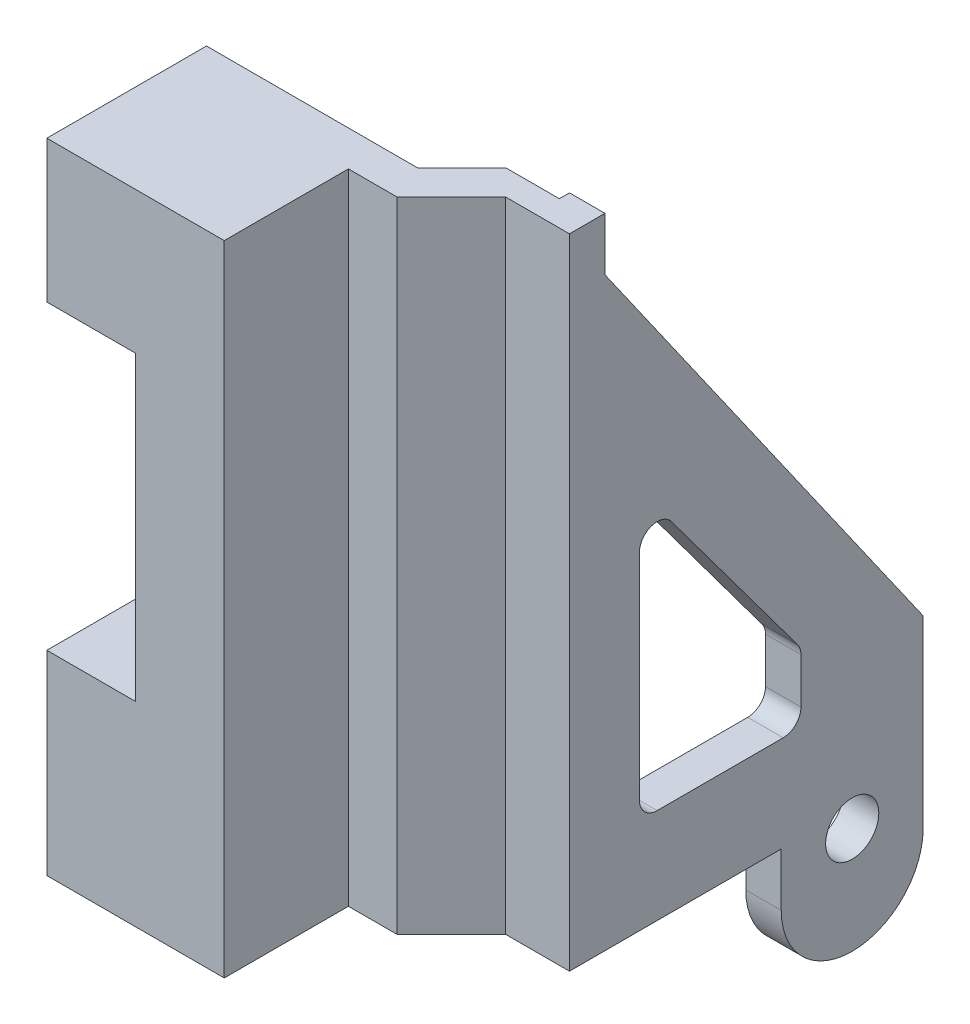
from build123d import *

# Parameters (mm, degrees)
BOSS_EXTRUDE1_DEPTH = 36
CUT_EXTRUDE1_REACH  = 21.399
CUT_EXTRUDE2_REACH  = 21.399
BOSS_EXTRUDE2_DEPTH = 2
CUT_EXTRUDE3_REACH  = 11
SKETCH5_W           = 5
SKETCH5_H           = 17
CUT_EXTRUDE4_REACH  = 21.399
SKETCH6_R           = 1.5


with BuildPart() as part:
    # Sketch1 → Boss-Extrude1 (new body)
    with BuildSketch(Plane(origin=(0, 0, 0), x_dir=(1, 0, 0), z_dir=(0, 1, 0))):
        Polygon((0, 0), (11.909668113, 0), (14.399319728, 2.489651615), (17.399319728, 2.489651615), (17.399319728, 21), (19.399319728, 21), (19.399319728, 1.06122449), (15.799319728, 1.06122449), (12.738095238, -2), (10, -2), (10, -9), (0, -9), align=None)
    extrude(amount=BOSS_EXTRUDE1_DEPTH)

    # Sketch2 → Cut-Extrude1 (cut, up to next)
    with BuildSketch(Plane(origin=(19.399319728, 0, 0), x_dir=(0, 0, -1), z_dir=(1, 0, 0)), mode=Mode.PRIVATE) as cut_extrude1_sk1:
        Polygon((3.06122449, 36), (3.06122449, 33), (21, 7.380773512), (21, 36), align=None)
    cut_extrude1_tool1 = extrude(cut_extrude1_sk1.sketch, amount=-CUT_EXTRUDE1_REACH, mode=Mode.PRIVATE) & part.part
    add(cut_extrude1_tool1.solids().sort_by_distance((19.39932, 26.365379, -14.453071))[0], mode=Mode.SUBTRACT)

    # Sketch3 → Cut-Extrude2 (cut, up to next)
    with BuildSketch(Plane(origin=(19.399319728, 0, 0), x_dir=(0, 0, -1), z_dir=(1, 0, 0)), mode=Mode.PRIVATE) as cut_extrude2_sk1:
        with BuildLine():
            Line((6.80922077, 19.075125289), (13.914682933, 9.520466295))
            ThreePointArc((13.914682933, 9.520466295), (14.061573755, 9.238022803), (14.112249375, 8.923724822))
            Line((14.112249375, 8.923724822), (14.112249375, 6.370604423))
            ThreePointArc((14.112249375, 6.370604423), (13.819356156, 5.663497642), (13.112249375, 5.370604423))
            Line((13.112249375, 5.370604423), (6.006787212, 5.370604423))
            ThreePointArc((6.006787212, 5.370604423), (5.299680431, 5.663497642), (5.006787212, 6.370604423))
            Line((5.006787212, 6.370604423), (5.006787212, 18.478383816))
            ThreePointArc((5.006787212, 18.478383816), (5.692489231, 19.427708197), (6.80922077, 19.075125289))
        make_face()
    cut_extrude2_tool1 = extrude(cut_extrude2_sk1.sketch, amount=-CUT_EXTRUDE2_REACH, mode=Mode.PRIVATE) & part.part
    add(cut_extrude2_tool1.solids().sort_by_distance((19.39932, 10.844583, -8.68829))[0], mode=Mode.SUBTRACT)

    # Sketch4 → Boss-Extrude2 (add)
    with BuildSketch(Plane(origin=(19.399319728, 0, 0), x_dir=(0, 0, -1), z_dir=(1, 0, 0))):
        with BuildLine():
            Line((21, 0), (21, -3))
            ThreePointArc((21, -3), (17, -7), (13, -3))
            Line((13, -3), (13, 0))
            Line((13, 0), (21, 0))
        make_face()
    extrude(amount=-BOSS_EXTRUDE2_DEPTH)

    # Sketch5 → Cut-Extrude3 (cut, up to next)
    with BuildSketch(Plane(origin=(0, 0, 0), x_dir=(-1, 0, 0), z_dir=(0, 0, -1)), mode=Mode.PRIVATE) as cut_extrude3_sk1:
        with Locations((-2.5, 19.5)):
            Rectangle(SKETCH5_W, SKETCH5_H)
    cut_extrude3_tool1 = extrude(cut_extrude3_sk1.sketch, amount=-CUT_EXTRUDE3_REACH, mode=Mode.PRIVATE) & part.part
    add(cut_extrude3_tool1.solids().sort_by_distance((2.5, 19.5, 0))[0], mode=Mode.SUBTRACT)

    # Sketch6 → Cut-Extrude4 (cut, up to next)
    with BuildSketch(Plane(origin=(19.399319728, 0, 0), x_dir=(0, 0, -1), z_dir=(1, 0, 0)), mode=Mode.PRIVATE) as cut_extrude4_sk1:
        with Locations((17, -1)):
            Circle(SKETCH6_R)
    cut_extrude4_tool1 = extrude(cut_extrude4_sk1.sketch, amount=-CUT_EXTRUDE4_REACH, mode=Mode.PRIVATE) & part.part
    add(cut_extrude4_tool1.solids().sort_by_distance((19.39932, -1, -17))[0], mode=Mode.SUBTRACT)


solid = part.part
